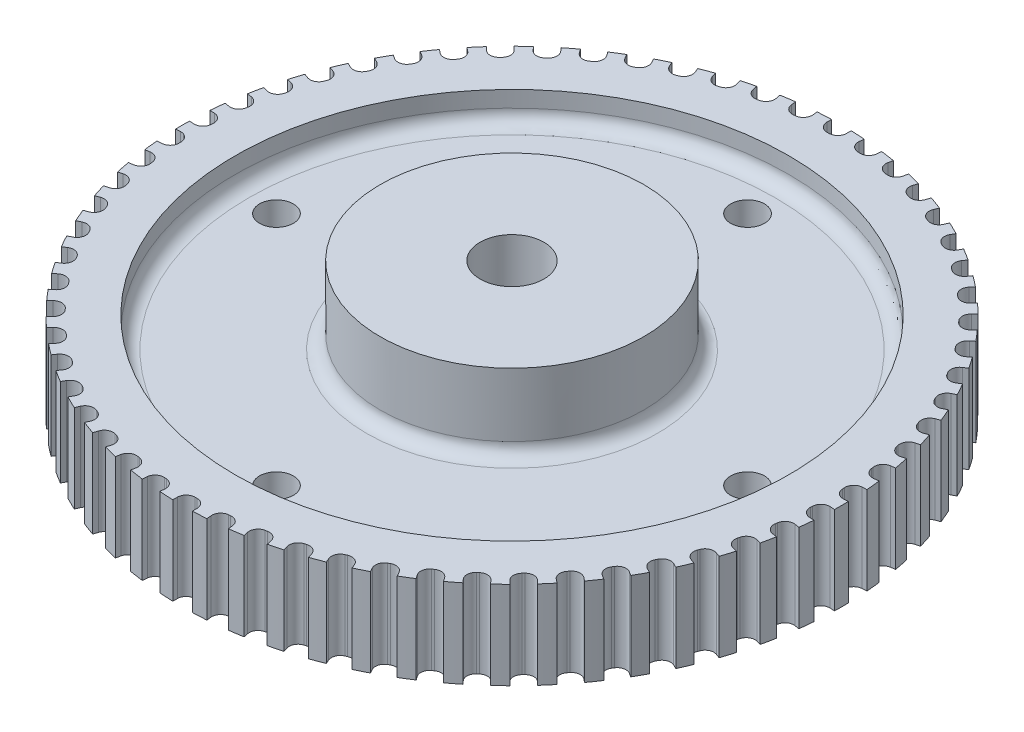
from build123d import *

# Parameters (mm, degrees)
FILETE1_R             = 2
ESBO_O2_R             = 2.5
CORTE_EXTRUS_O1_DEPTH = 21
CORTE_EXTRUS_O2_DEPTH = 14
PADR_OCIRCULAR1_COUNT = 62


with BuildPart() as part:
    # Esboço1 → Revolução1 (revolve)
    with BuildSketch(Plane.XY):
        Polygon((4.725, 0), (4.725, 20), (19.5, 20), (19.5, 8.6), (40.925, 8.6), (40.925, 13), (48.75, 13), (48.75, 0), (40.925, 0), (40.925, 4.5), (19.5, 4.5), (19.5, 0), align=None)
    revolve(axis=Axis((0, 0, 0), (0, 1, 0)))

    # Filete1
    filete1_edges = [part.edges().sort_by_distance(p)[0] for p in [
        (-40.925, 4.5, 0),
        (-40.925, 8.6, 0),
        (-19.5, 8.6, 0),
        (-19.5, 4.5, 0),
    ]]
    fillet(filete1_edges, radius=FILETE1_R)

    # Esboço2 → Corte-extrusão1 (cut, through all)
    with BuildSketch(Plane(origin=(0, 0, 0), x_dir=(1, 0, 0), z_dir=(0, 1, 0))):
        with Locations((0, 34.85)):
            Circle(ESBO_O2_R)
        with Locations((0, -34.85)):
            Circle(ESBO_O2_R)
        with Locations((34.85, 0)):
            Circle(ESBO_O2_R)
        with Locations((-34.85, 0)):
            Circle(ESBO_O2_R)
    extrude(amount=CORTE_EXTRUS_O1_DEPTH, mode=Mode.SUBTRACT)

    # Esboço3 → Corte-extrusão2 (cut, through all)
    with BuildSketch(Plane(origin=(0, 13, 0), x_dir=(1, 0, 0), z_dir=(0, 1, 0))):
        with BuildLine():
            Line((-1.45, 50.567198435), (1.45, 50.567198435))
            Line((1.45, 50.567198435), (1.45, 48.05))
            ThreePointArc((1.45, 48.05), (1.069238816, 47.130761184), (0.15, 46.75))
            Line((0.15, 46.75), (-0.15, 46.75))
            ThreePointArc((-0.15, 46.75), (-1.069238816, 47.130761184), (-1.45, 48.05))
            Line((-1.45, 48.05), (-1.45, 50.567198435))
        make_face()
    corte_extrus_o2 = extrude(amount=-CORTE_EXTRUS_O2_DEPTH, mode=Mode.SUBTRACT)

    # PadrãoCircular1: Corte-extrusão2 ×62 about axis
    padr_ocircular1_axis = Axis((0, 0, 0), (0, 1, 0))
    for i in range(1, PADR_OCIRCULAR1_COUNT):
        add(corte_extrus_o2.rotate(padr_ocircular1_axis, i * 360 / PADR_OCIRCULAR1_COUNT), mode=Mode.SUBTRACT)


solid = part.part
